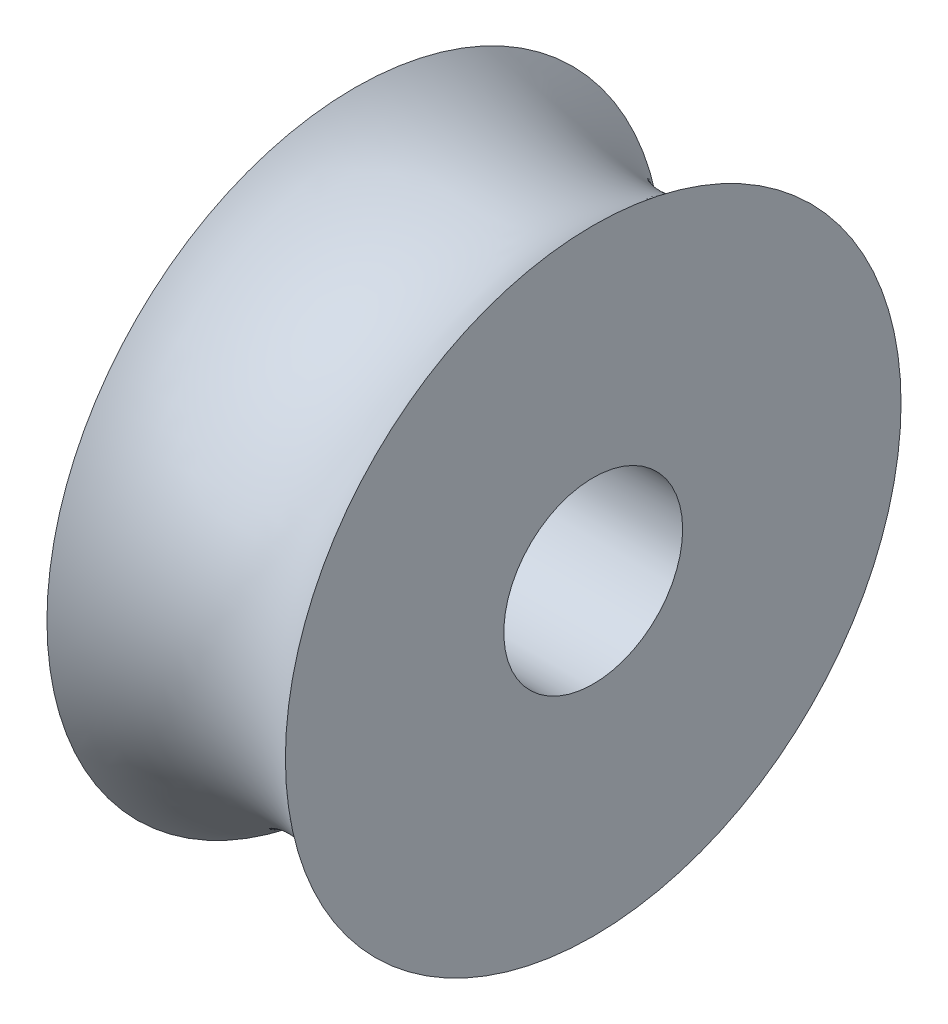
from build123d import *

# Parameters (mm, degrees)
SKETCH2_R          = 2.38125
CUT_EXTRUDE1_DEPTH = 7.35


with BuildPart() as part:
    # Sketch1 → Revolve1 (revolve)
    with BuildSketch(Plane.XY):
        with BuildLine():
            Line((-3.175, 0), (3.175, 0))
            Line((3.175, 0), (3.175, 8.197742086))
            ThreePointArc((3.175, 8.197742086), (0, 6.985), (-3.175, 8.197742086))
            Line((-3.175, 8.197742086), (-3.175, 0))
        make_face()
    revolve(axis=Axis((-3.175, 0, 0), (1, 0, 0)))

    # Sketch2 → Cut-Extrude1 (cut, through all)
    with BuildSketch(Plane(origin=(3.175, 0, 0), x_dir=(0, 0, -1), z_dir=(1, 0, 0))):
        Circle(SKETCH2_R)
    extrude(amount=-CUT_EXTRUDE1_DEPTH, mode=Mode.SUBTRACT)


solid = part.part
